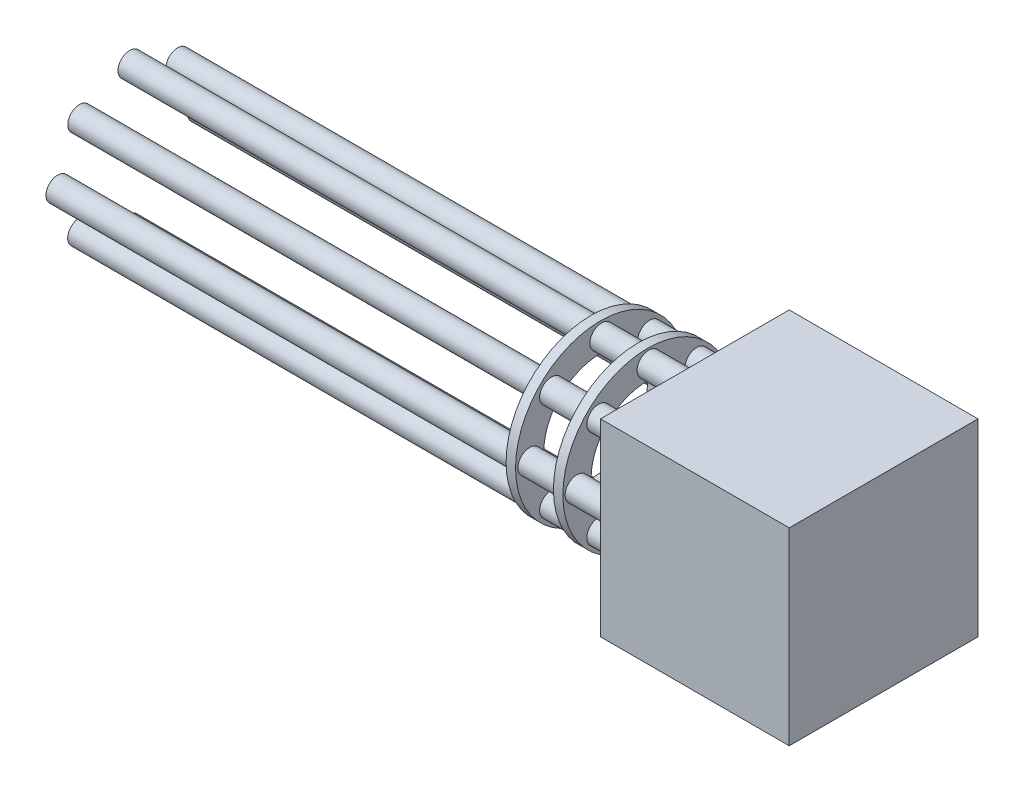
from build123d import *

# Parameters (mm, degrees)
SKETCH1_W               = 2000
SKETCH1_H               = 2000
BOSS_EXTRUDE1_DEPTH     = 2000
SKETCH2_R               = 501.404067121
CUT_EXTRUDE1_DEPTH      = 500
SKETCH7_R               = 124.554689767
SKETCH7_R_2             = 125
SKETCH7_R_3             = 124.427032374
BOSS_EXTRUDE4_DEPTH     = 6000
SKETCH9_R               = 900
BOSS_EXTRUDE6_DEPTH     = 100
SKETCH10_R              = 898.565766003
BOSS_EXTRUDE7_DEPTH     = 100
CUT_EXTRUDE2_DEPTH      = 600
CUT_EXTRUDE2_DEPTH_BACK = 600
SKETCH9_3_R             = 600
CUT_EXTRUDE3_DEPTH      = 5745.562646538
CUT_EXTRUDE3_DEPTH_BACK = 1000
SKETCH11_R              = 98.351136435
SKETCH11_R_2            = 100.031302244
SKETCH11_R_3            = 100.947048472
SKETCH11_R_4            = 103.636751453
SKETCH11_R_5            = 97.314563003
SKETCH11_R_6            = 98.619776391
SKETCH11_R_7            = 100.318526813
SKETCH11_R_8            = 101.297019076


with BuildPart() as part:
    # Sketch1 → Boss-Extrude1 (new body)
    with BuildSketch(Plane.XY):
        with Locations((1000, 1000)):
            Rectangle(SKETCH1_W, SKETCH1_H)
    extrude(amount=BOSS_EXTRUDE1_DEPTH)

    # Sketch4 → Cut-Revolve1 (revolve, cut)
    with BuildSketch(Plane(origin=(1000, 0, 0), x_dir=(0, 0, -1), z_dir=(1, 0, 0))):
        with BuildLine():
            Line((-1750, 1000), (-150, 1000))
            ThreePointArc((-150, 1000), (-950, 200), (-1750, 1000))
        make_face()
    revolve(axis=Axis((1000, 1000, 1750), (0, 0, -1)), mode=Mode.SUBTRACT)

    # Sketch2 → Cut-Extrude1 (cut)
    with BuildSketch(Plane.XY):
        with Locations((1000, 1000)):
            Circle(SKETCH2_R)
    extrude(amount=CUT_EXTRUDE1_DEPTH, mode=Mode.SUBTRACT)

    # Sketch7 → Boss-Extrude4 (add)
    with BuildSketch(Plane(origin=(0, 0, 0), x_dir=(0, 0, -1), z_dir=(1, 0, 0))):
        with Locations((-987.552819521, 1750)):
            Circle(SKETCH7_R)
        with Locations((-1750, 987.552819521)):
            Circle(SKETCH7_R_2)
        with Locations((-1000, 250)):
            Circle(SKETCH7_R_2)
        with Locations((-250, 987.552819521)):
            Circle(SKETCH7_R_2)
        with Locations((-480, 1520)):
            Circle(SKETCH7_R_2)
        with Locations((-1520, 1520)):
            Circle(SKETCH7_R_3)
        with Locations((-1520, 480)):
            Circle(SKETCH7_R_2)
        with Locations((-480, 480)):
            Circle(SKETCH7_R_2)
    extrude(amount=-BOSS_EXTRUDE4_DEPTH)

    # Sketch9 → Boss-Extrude6 (add)
    with BuildSketch(Plane.ZY.offset(1000)):
        with Locations((1000, 1000)):
            Circle(SKETCH9_R)
    extrude(amount=BOSS_EXTRUDE6_DEPTH)

    # Sketch10 → Boss-Extrude7 (add)
    with BuildSketch(Plane.ZY.offset(500)):
        with Locations((1000, 1000)):
            Circle(SKETCH10_R)
    extrude(amount=BOSS_EXTRUDE7_DEPTH)

    # Sketch9_3 → Cut-Extrude2 (cut, two sides: drawn at the far end of the back side and taken through both)
    with BuildSketch(Plane.ZY.offset(1000).offset(-CUT_EXTRUDE2_DEPTH_BACK)):
        with Locations((1000, 1000)):
            Circle(SKETCH9_3_R)
    extrude(amount=CUT_EXTRUDE2_DEPTH + CUT_EXTRUDE2_DEPTH_BACK, mode=Mode.SUBTRACT)

    # Sketch11 → Cut-Extrude3 (cut, two sides: drawn at the far end of the back side and taken through both)
    with BuildSketch(Plane.ZY.offset(1000).offset(-CUT_EXTRUDE3_DEPTH_BACK)):
        with Locations((480, 1520)):
            Circle(SKETCH11_R)
        with Locations((987.552819521, 1750)):
            Circle(SKETCH11_R_2)
        with Locations((480, 480)):
            Circle(SKETCH11_R_3)
        with Locations((1000, 250)):
            Circle(SKETCH11_R_4)
        with Locations((1520, 480)):
            Circle(SKETCH11_R_5)
        with Locations((1750, 987.552819521)):
            Circle(SKETCH11_R_6)
        with Locations((1520, 1520)):
            Circle(SKETCH11_R_7)
        with Locations((250, 987.552819521)):
            Circle(SKETCH11_R_8)
    extrude(amount=CUT_EXTRUDE3_DEPTH + CUT_EXTRUDE3_DEPTH_BACK, mode=Mode.SUBTRACT)


solid = part.part
